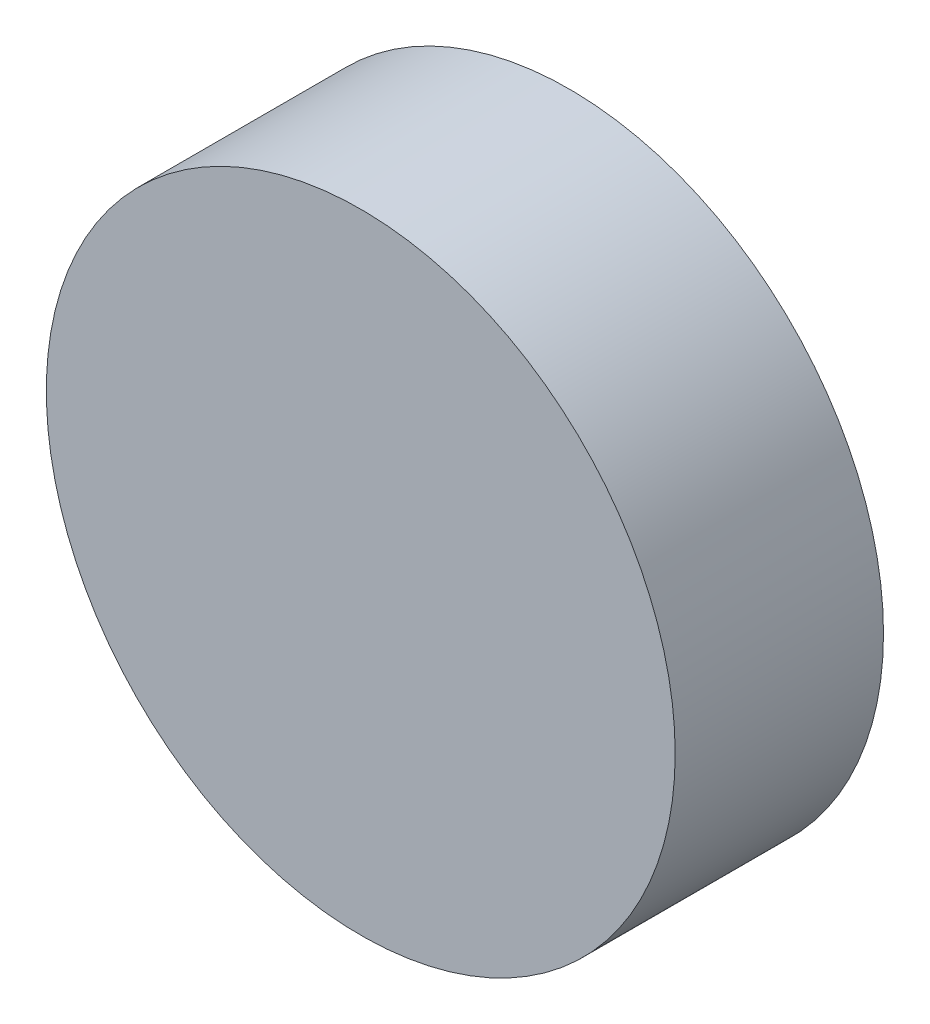
from build123d import *

# Parameters (mm, degrees)
SKETCH_1_R      = 4
EXTRUDE_1_DEPTH = 2.65


with BuildPart() as part:
    # 草图1 → 凸台-拉伸1 (new body)
    with BuildSketch(Plane.XY):
        Circle(SKETCH_1_R)
    extrude(amount=EXTRUDE_1_DEPTH)


solid = part.part
